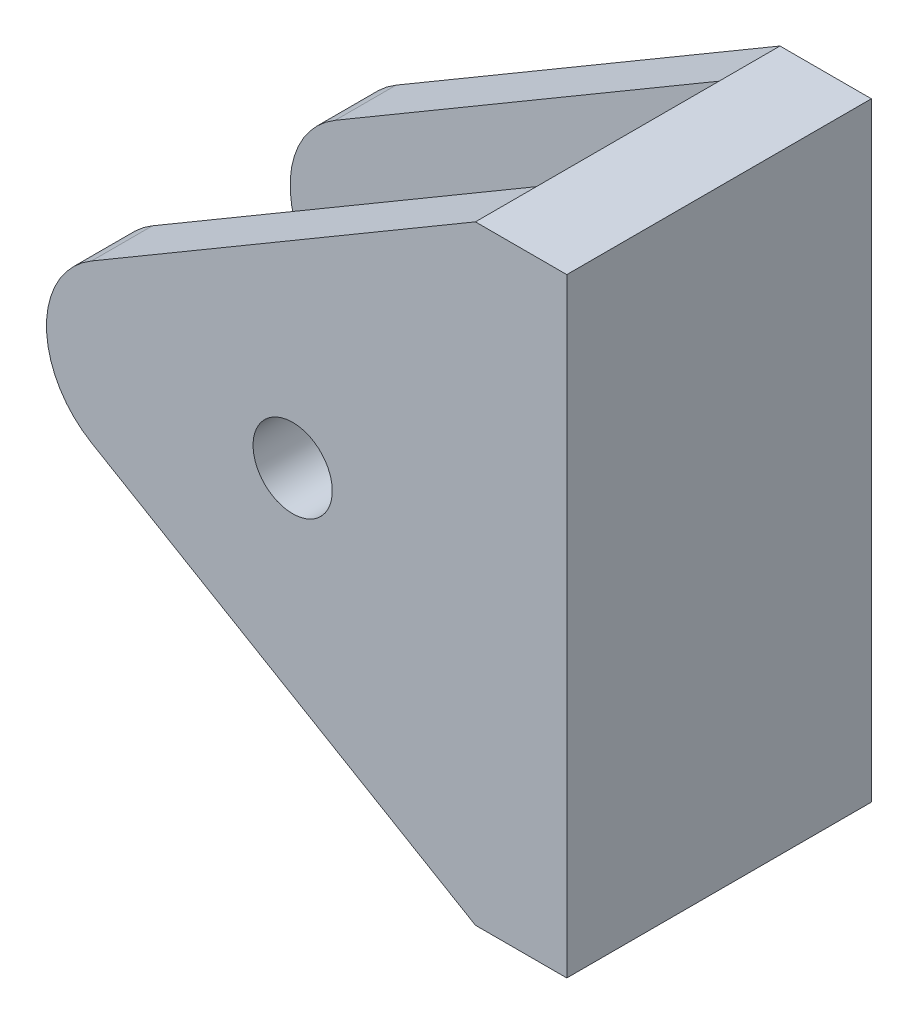
from build123d import *

# Parameters (mm, degrees)
DODANIE_WYCI_GNI_CIE3_DEPTH = 10
SZKIC4_W                    = 6
SZKIC4_H                    = 24.913855362
WYTNIJ_WYCI_GNI_CIE2_DEPTH  = 22
OTW_R_POD_RUB_M21_D         = 2.6


with BuildPart() as part:
    # Szkic3 → Dodanie-wyciągnięcie3 (new body)
    with BuildSketch(Plane.XY):
        with BuildLine():
            Line((0, -10), (0, 10))
            Line((0, 10), (-3, 10))
            Line((-3, 10), (-15.604135503, 2.585802645))
            ThreePointArc((-15.604135503, 2.585802645), (-17.083075123, 0), (-15.604135503, -2.585802645))
            Line((-15.604135503, -2.585802645), (-3, -10))
            Line((-3, -10), (0, -10))
        make_face()
    extrude(amount=DODANIE_WYCI_GNI_CIE3_DEPTH)

    # Szkic4 → Wytnij-wyciągnięcie2 (cut)
    with BuildSketch(Plane(origin=(-25, 0, 0), x_dir=(0, 0, -1), z_dir=(1, 0, 0))):
        with Locations((-5, 0)):
            Rectangle(SZKIC4_W, SZKIC4_H)
    extrude(amount=WYTNIJ_WYCI_GNI_CIE2_DEPTH, mode=Mode.SUBTRACT)

    # Otwór pod śrubę M21 (through all)
    with Locations(Plane.XY.offset(10)):
        with Locations((-9, 0)):
            Hole(OTW_R_POD_RUB_M21_D / 2)


solid = part.part
